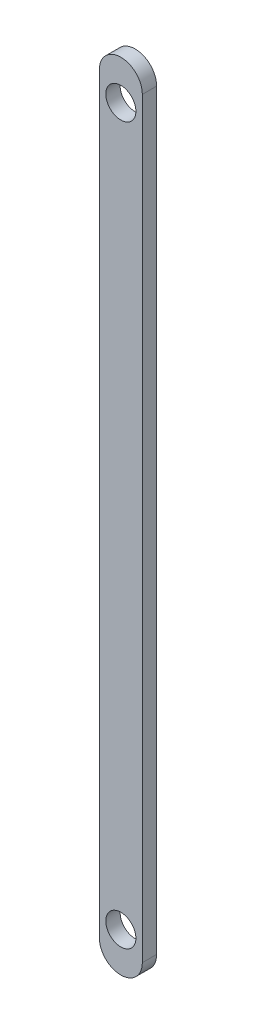
from build123d import *

# Parameters (mm, degrees)
EXTRUDE_1_DEPTH     = 2
SKETCH_2_R          = 2.1
CUT_EXTRUDE_1_DEPTH = 3


with BuildPart() as part:
    # 草圖1 → 填料-伸長1 (new body)
    with BuildSketch(Plane.XY):
        with BuildLine():
            Line((-3, -52.5), (-3, 52.5))
            ThreePointArc((-3, 52.5), (0, 55.5), (3, 52.5))
            Line((3, 52.5), (3, -52.5))
            ThreePointArc((3, -52.5), (0, -55.5), (-3, -52.5))
        make_face()
    extrude(amount=EXTRUDE_1_DEPTH)

    # 草圖2 → 除料-伸長1 (cut, through all)
    with BuildSketch(Plane.XY.offset(2)):
        with Locations((0, 50)):
            Circle(SKETCH_2_R)
        with Locations((0, -50)):
            Circle(SKETCH_2_R)
    extrude(amount=-CUT_EXTRUDE_1_DEPTH, mode=Mode.SUBTRACT)


solid = part.part
